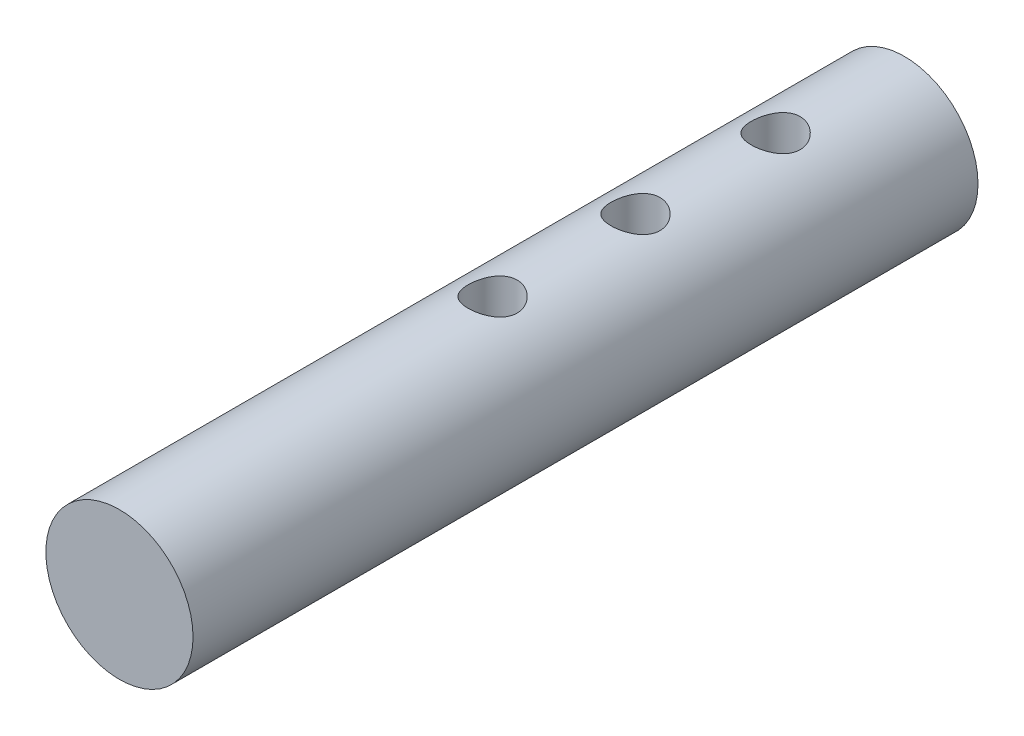
from build123d import *

# Parameters (mm, degrees)
SKETCH1_R                        = 19.05
BOSS_EXTRUDE1_DEPTH              = 203.2
F_97_0_0059_DIAMETER_HOLE1_D     = 12.7
F_97_0_0059_DIAMETER_HOLE1_DEPTH = 210.058
F_97_0_0059_DIAMETER_HOLE1_TIP   = 3.815464931


with BuildPart() as part:
    # Sketch1 → Boss-Extrude1 (new body)
    with BuildSketch(Plane.XY):
        Circle(SKETCH1_R)
    extrude(amount=BOSS_EXTRUDE1_DEPTH)

    # #97 (0.0059) Diameter Hole1
    with Locations(Plane(origin=(0, 19.05, 33.344821803), x_dir=(1, 0, 0), z_dir=(0, 1, 0))):
        with Locations((0, 0), (0, -36.275479321), (0, -73.266922051)):
            Hole(F_97_0_0059_DIAMETER_HOLE1_D / 2, depth=F_97_0_0059_DIAMETER_HOLE1_DEPTH)
            with Locations((0, 0, -(F_97_0_0059_DIAMETER_HOLE1_DEPTH + F_97_0_0059_DIAMETER_HOLE1_TIP / 2))):  # 118° drill point
                Cone(0, F_97_0_0059_DIAMETER_HOLE1_D / 2, F_97_0_0059_DIAMETER_HOLE1_TIP, mode=Mode.SUBTRACT)


solid = part.part
